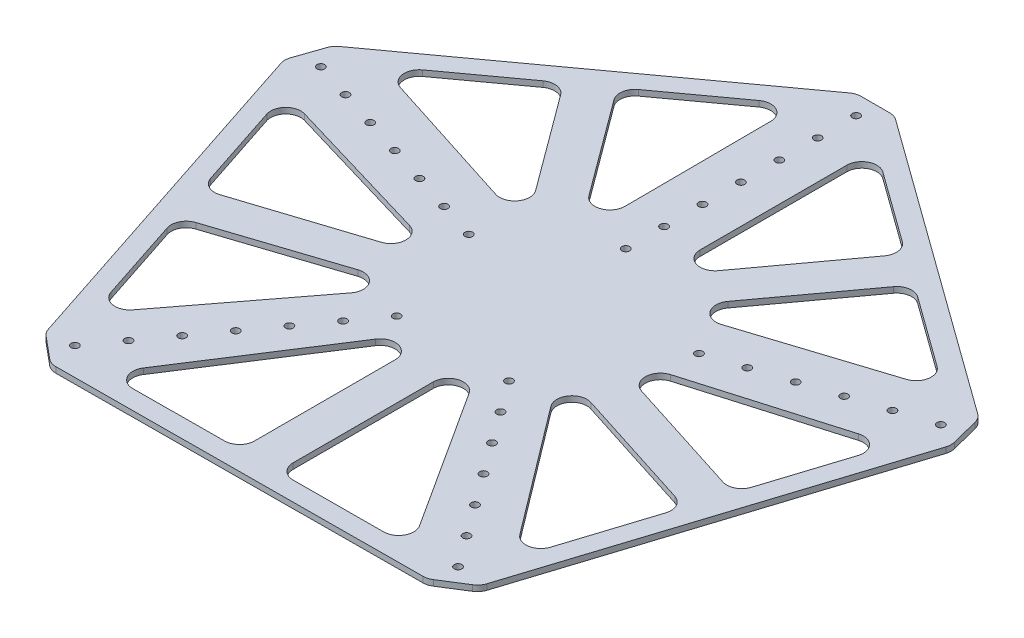
from build123d import *

# Parameters (mm, degrees)
BOSS_EXTRUDE1_DEPTH = 3.81
SKETCH1_R           = 2.54
CUT_EXTRUDE2_DEPTH  = 3.81
CUT_EXTRUDE4_DEPTH  = 25.4
FILLET1_R           = 10
CUT_EXTRUDE5_DEPTH  = 25.4
FILLET2_R           = 10
FILLET3_R           = 10


with BuildPart() as part:
    # Sketch2 → Boss-Extrude1 (new body)
    with BuildSketch(Plane(origin=(0, 0, 0), x_dir=(1, 0, 0), z_dir=(0, 1, 0))):
        Polygon((-214.113347974, 82.923214231), (-222.375187677, 58.900508182), (-144.642224503, -177.47641221), (-125.09137467, -193.780037034), (124.093192846, -192.406157618), (145.640406327, -178.850291626), (221.336035454, 58.562867157), (215.102095915, 83.244477912), (12.7, 229.477457482), (-12.7, 229.477457482), align=None)
    extrude(amount=BOSS_EXTRUDE1_DEPTH)

    # Sketch1 → Cut-Extrude2 (cut)
    with BuildSketch(Plane(origin=(0, 0, 0), x_dir=(1, 0, 0), z_dir=(0, 1, 0))):
        with Locations((0, 63.524373819)):
            Circle(SKETCH1_R)
        with Locations((0, 89.046242914)):
            Circle(SKETCH1_R)
        with Locations((0, 114.568112009)):
            Circle(SKETCH1_R)
        with Locations((0, 140.089981103)):
            Circle(SKETCH1_R)
        with Locations((0, 165.611850198)):
            Circle(SKETCH1_R)
        with Locations((0, 191.133719293)):
            Circle(SKETCH1_R)
        with Locations((0, 216.655588388)):
            Circle(SKETCH1_R)
        with Locations((84.688009575, 27.516802346)):
            Circle(SKETCH1_R)
        with Locations((108.960749485, 35.403493624)):
            Circle(SKETCH1_R)
        with Locations((133.233489396, 43.290184903)):
            Circle(SKETCH1_R)
        with Locations((157.506229307, 51.176876181)):
            Circle(SKETCH1_R)
        with Locations((181.778969217, 59.06356746)):
            Circle(SKETCH1_R)
        with Locations((206.051709128, 66.950258738)):
            Circle(SKETCH1_R)
        with Locations((37.338690092, -51.392297977)):
            Circle(SKETCH1_R)
        with Locations((52.340068357, -72.039923802)):
            Circle(SKETCH1_R)
        with Locations((67.341446622, -92.687549628)):
            Circle(SKETCH1_R)
        with Locations((82.342824886, -113.335175454)):
            Circle(SKETCH1_R)
        with Locations((97.344203151, -133.98280128)):
            Circle(SKETCH1_R)
        with Locations((112.345581416, -154.630427106)):
            Circle(SKETCH1_R)
        with Locations((127.346959681, -175.278052932)):
            Circle(SKETCH1_R)
        with Locations((-37.338690092, -51.392297977)):
            Circle(SKETCH1_R)
        with Locations((-52.340068357, -72.039923802)):
            Circle(SKETCH1_R)
        with Locations((-67.341446622, -92.687549628)):
            Circle(SKETCH1_R)
        with Locations((-82.342824886, -113.335175454)):
            Circle(SKETCH1_R)
        with Locations((-97.344203151, -133.98280128)):
            Circle(SKETCH1_R)
        with Locations((-112.345581416, -154.630427106)):
            Circle(SKETCH1_R)
        with Locations((-127.346959681, -175.278052932)):
            Circle(SKETCH1_R)
        with Locations((-60.415269664, 19.630111067)):
            Circle(SKETCH1_R)
        with Locations((-84.688009575, 27.516802346)):
            Circle(SKETCH1_R)
        with Locations((-108.960749485, 35.403493624)):
            Circle(SKETCH1_R)
        with Locations((-133.233489396, 43.290184903)):
            Circle(SKETCH1_R)
        with Locations((-157.506229307, 51.176876181)):
            Circle(SKETCH1_R)
        with Locations((-181.778969217, 59.06356746)):
            Circle(SKETCH1_R)
        with Locations((-206.051709128, 66.950258738)):
            Circle(SKETCH1_R)
    extrude(amount=CUT_EXTRUDE2_DEPTH, mode=Mode.SUBTRACT)

    # Sketch4 → Cut-Extrude4 (cut)
    with BuildSketch(Plane(origin=(0, 3.81, 0), x_dir=(1, 0, 0), z_dir=(0, 1, 0))):
        Polygon((-45.070854373, 42.218517188), (-116.134569677, 138.509259641), (-186.385554028, 87.392588613), align=None)
    extrude(amount=-CUT_EXTRUDE4_DEPTH, mode=Mode.SUBTRACT)

    # Fillet1
    fillet1_edges = [part.edges().sort_by_distance(p)[0] for p in [
        (-186.385554028, 1.905, -87.392588613),
        (-45.070854373, 1.905, -42.218517188),
        (-116.134569677, 1.905, -138.509259641),
    ]]
    fillet(fillet1_edges, radius=FILLET1_R)

    # Sketch4_3 → Cut-Extrude5 (cut)
    with BuildSketch(Plane(origin=(0, 3.81, 0), x_dir=(1, 0, 0), z_dir=(0, 1, 0))):
        Polygon((-45.070854373, 42.218517188), (-116.134569677, 138.509259641), (-186.385554028, 87.392588613), align=None)
        Polygon((-25.263196152, 204.629928972), (-95.595688183, 153.453950571), (-24.449522239, 57.051488188), align=None)
        Polygon((96.100640401, 153.553690969), (25.4, 204.634018259), (25.4, 57.052227702), align=None)
        Polygon((46.069621628, 42.286739176), (116.689753838, 138.678314353), (187.309886047, 87.656153224), align=None)
        Polygon((-54.313264472, -4.068117885), (-202.740299234, 39.846930078), (-175.394631138, -43.308073239), align=None)
        Polygon((-46.329229165, -27.545327403), (-167.47690719, -67.384952942), (-140.115544314, -150.587682263), align=None)
        Polygon((-12.7, -43.090401677), (-101.684923108, -180.937649266), (-12.7, -180.397220358), align=None)
        Polygon((12.7, -43.122873263), (12.7, -180.257313283), (100.864034479, -179.820968664), align=None)
        Polygon((46.904199543, -26.956649015), (140.994368681, -151.614087132), (168.389811964, -65.690516628), align=None)
        Polygon((56.068689502, -3.218822472), (201.972389344, 39.638494676), (176.105537606, -41.490773287), align=None)
    extrude(amount=-CUT_EXTRUDE5_DEPTH, mode=Mode.SUBTRACT)

    # Fillet2
    fillet2_edges = [part.edges().sort_by_distance(p)[0] for p in [
        (96.100640401, 1.905, -153.553690969),
        (25.4, 1.905, -204.634018259),
        (25.4, 1.905, -57.052227702),
        (116.689753838, 1.905, -138.678314353),
        (46.069621628, 1.905, -42.286739176),
        (187.309886047, 1.905, -87.656153224),
        (56.068689502, 1.905, 3.218822472),
        (176.105537606, 1.905, 41.490773287),
        (201.972389344, 1.905, -39.638494676),
        (46.904199543, 1.905, 26.956649015),
        (140.994368681, 1.905, 151.614087132),
        (168.389811964, 1.905, 65.690516628),
        (12.7, 1.905, 180.257313283),
        (100.864034479, 1.905, 179.820968664),
        (12.7, 1.905, 43.122873263),
        (-12.7, 1.905, 43.090401677),
        (-101.684923108, 1.905, 180.937649266),
        (-12.7, 1.905, 180.397220358),
        (-54.313264472, 1.905, 4.068117885),
        (-175.394631138, 1.905, 43.308073239),
        (-202.740299234, 1.905, -39.846930078),
        (-167.47690719, 1.905, 67.384952942),
        (-140.115544314, 1.905, 150.587682263),
        (-46.329229165, 1.905, 27.545327403),
        (-24.449522239, 1.905, -57.051488188),
        (-25.263196152, 1.905, -204.629928972),
        (-95.595688183, 1.905, -153.453950571),
        (-45.070854373, 1.905, -42.218517188),
        (-116.134569677, 1.905, -138.509259641),
        (-186.385554028, 1.905, -87.392588613),
    ]]
    fillet(fillet2_edges, radius=FILLET2_R)

    # Fillet3
    fillet3_edges = [part.edges().sort_by_distance(p)[0] for p in [
        (-12.7, 1.905, -229.477457482),
        (12.7, 1.905, -229.477457482),
        (215.102095915, 1.905, -83.244477912),
        (221.336035454, 1.905, -58.562867157),
        (145.640406327, 1.905, 178.850291626),
        (124.093192846, 1.905, 192.406157618),
        (-125.09137467, 1.905, 193.780037034),
        (-144.642224503, 1.905, 177.47641221),
        (-222.375187677, 1.905, -58.900508182),
        (-214.113347974, 1.905, -82.923214231),
    ]]
    fillet(fillet3_edges, radius=FILLET3_R)


solid = part.part
